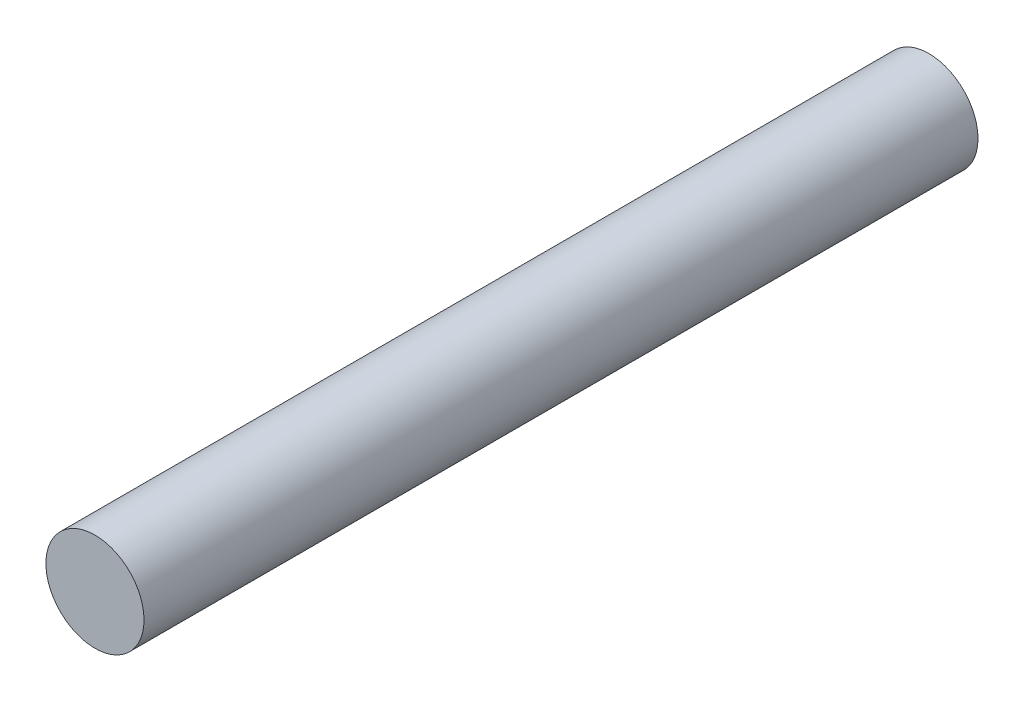
from build123d import *

# Parameters (mm, degrees)
SKETCH1_R           = 5
BOSS_EXTRUDE1_DEPTH = 85


with BuildPart() as part:
    # Sketch1 → Boss-Extrude1 (new body)
    with BuildSketch(Plane.XY):
        Circle(SKETCH1_R)
    extrude(amount=BOSS_EXTRUDE1_DEPTH)


solid = part.part
